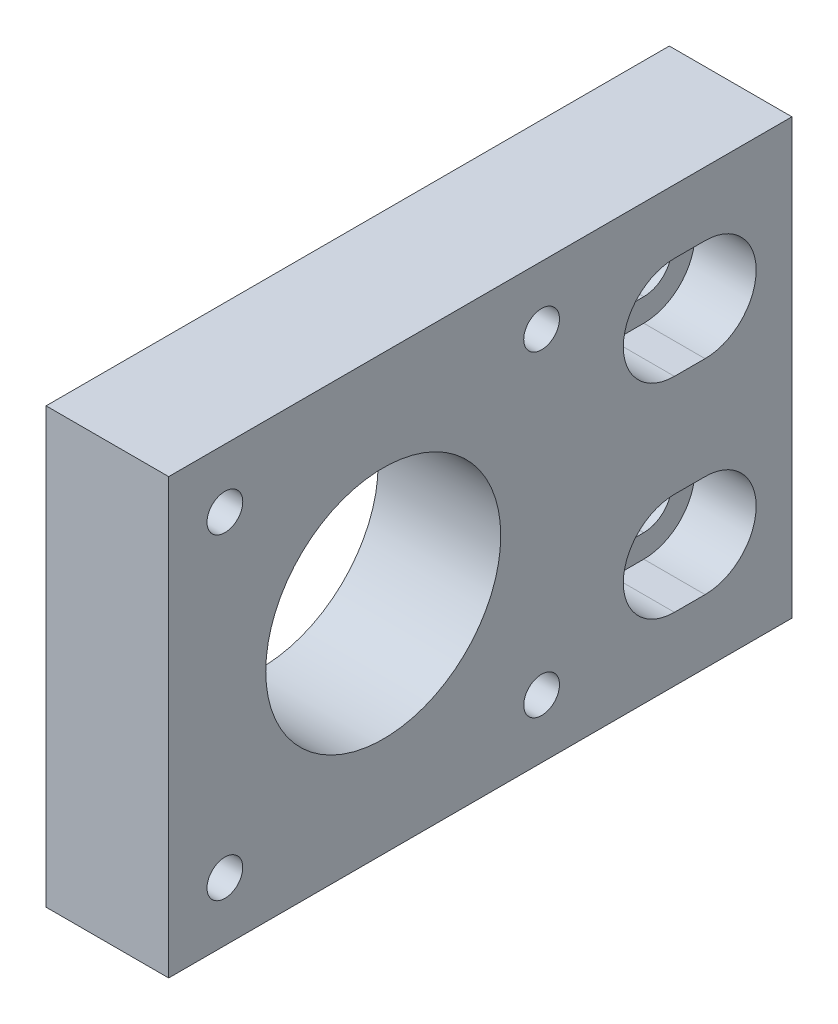
from build123d import *

# Parameters (mm, degrees)
SKETCH2_W           = 61
SKETCH2_H           = 42.5
SKETCH2_R           = 11.5
SKETCH2_R_2         = 1.75
BOSS_EXTRUDE2_DEPTH = 12
CUT_EXTRUDE1_DEPTH  = 6


with BuildPart() as part:
    # Sketch2 → Boss-Extrude2 (new body)
    with BuildSketch(Plane(origin=(0, 0, 0), x_dir=(0, 0, -1), z_dir=(1, 0, 0))):
        with Locations((9.5, 0)):
            Rectangle(SKETCH2_W, SKETCH2_H)
        Circle(SKETCH2_R, mode=Mode.SUBTRACT)
        with Locations((-15.5, 15.5)):
            Circle(SKETCH2_R_2, mode=Mode.SUBTRACT)
        with Locations((15.5, -15.5)):
            Circle(SKETCH2_R_2, mode=Mode.SUBTRACT)
        with Locations((15.5, 15.5)):
            Circle(SKETCH2_R_2, mode=Mode.SUBTRACT)
        with Locations((-15.5, -15.5)):
            Circle(SKETCH2_R_2, mode=Mode.SUBTRACT)
        with BuildLine():
            Line((28.5, 12.75), (31.5, 12.75))
            ThreePointArc((31.5, 12.75), (34.25, 10), (31.5, 7.25))
            Line((31.5, 7.25), (28.5, 7.25))
            ThreePointArc((28.5, 7.25), (25.75, 10), (28.5, 12.75))
        make_face(mode=Mode.SUBTRACT)
        with BuildLine():
            Line((28.5, -12.75), (31.5, -12.75))
            ThreePointArc((31.5, -12.75), (34.25, -10), (31.5, -7.25))
            Line((31.5, -7.25), (28.5, -7.25))
            ThreePointArc((28.5, -7.25), (25.75, -10), (28.5, -12.75))
        make_face(mode=Mode.SUBTRACT)
    extrude(amount=BOSS_EXTRUDE2_DEPTH)

    # Sketch3 → Cut-Extrude1 (cut)
    with BuildSketch(Plane(origin=(12, 0, 0), x_dir=(0, 0, -1), z_dir=(1, 0, 0))):
        with BuildLine():
            Line((28.5, 15), (31.5, 15))
            ThreePointArc((31.5, 15), (36.5, 10), (31.5, 5))
            Line((31.5, 5), (28.5, 5))
            ThreePointArc((28.5, 5), (23.5, 10), (28.5, 15))
        make_face()
        with BuildLine():
            Line((28.5, -15), (31.5, -15))
            ThreePointArc((31.5, -15), (36.5, -10), (31.5, -5))
            Line((31.5, -5), (28.5, -5))
            ThreePointArc((28.5, -5), (23.5, -10), (28.5, -15))
        make_face()
    extrude(amount=-CUT_EXTRUDE1_DEPTH, mode=Mode.SUBTRACT)


solid = part.part
